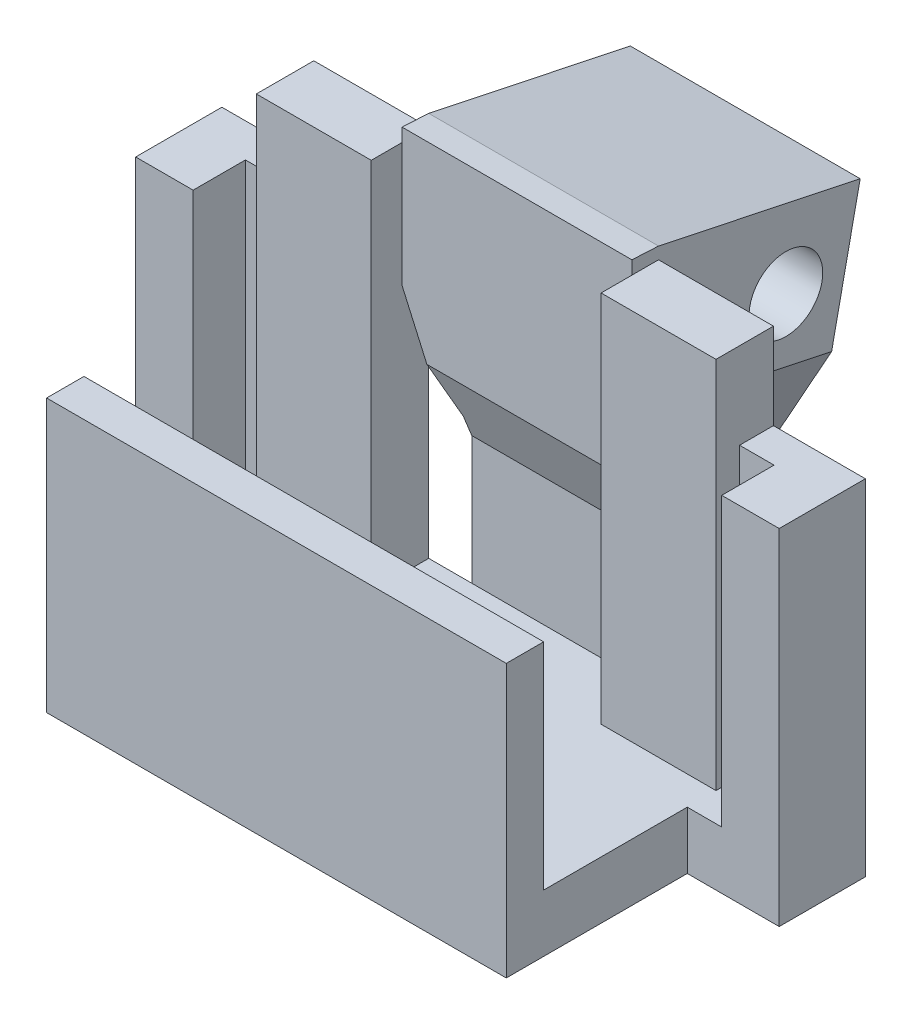
from build123d import *

# Parameters (mm, degrees)
SKETCH_1_W          = 16
SKETCH_1_H          = 6
EXTRUDE_1_DEPTH     = 2
SKETCH_1_3_W        = 16
SKETCH_1_3_H        = 2
SKETCH_1_3_H_2      = 1.5
EXTRUDE_2_DEPTH     = 15
SKETCH_2_W          = 8
SKETCH_2_H          = 26
CUT_EXTRUDE_1_DEPTH = 2
EXTRUDE_3_DEPTH     = 2.5
EXTRUDE_4_DEPTH     = 5
EXTRUDE_5_DEPTH     = 1.5
SKETCH_9_W          = 1.2
SKETCH_9_H          = 1.820432063
EXTRUDE_6_DEPTH     = 2
EXTRUDE_7_DEPTH     = 12
CUT_EXTRUDE_START   = -7.10494
CUT_EXTRUDE_2_DEPTH = 7.10494
SKETCH_12_R         = 1.281793471
CUT_EXTRUDE_3_DEPTH = 10
CUT_EXTRUDE_4_DEPTH = 20.2


with BuildPart() as part:
    # 草图1 → 凸台-拉伸1 (new body)
    with BuildSketch(Plane(origin=(0, 0, 0), x_dir=(1, 0, 0), z_dir=(0, 1, 0))):
        with Locations((0, -0.25)):
            Rectangle(SKETCH_1_W, SKETCH_1_H)
    extrude(amount=EXTRUDE_1_DEPTH)

    # 草图1<3> → 凸台-拉伸2 (add)
    with BuildSketch(Plane(origin=(0, 0, 0), x_dir=(1, 0, 0), z_dir=(0, 1, 0))):
        with Locations((0, 3.75)):
            Rectangle(SKETCH_1_3_W, SKETCH_1_3_H)
        with Locations((0, -4)):
            Rectangle(SKETCH_1_3_W, SKETCH_1_3_H_2)
    extrude(amount=EXTRUDE_2_DEPTH)

    # 草图2 → 切除-拉伸1 (cut)
    with BuildSketch(Plane(origin=(0, 0, -4.75), x_dir=(-1, 0, 0), z_dir=(0, 0, -1))):
        with Locations((0, 15)):
            Rectangle(SKETCH_2_W, SKETCH_2_H)
    extrude(amount=-CUT_EXTRUDE_1_DEPTH, mode=Mode.SUBTRACT)

    # 草图3 → 凸台-拉伸3 (add, symmetric)
    with BuildSketch(Plane(origin=(0, 0, 0), x_dir=(0, 0, -1), z_dir=(1, 0, 0))):
        Polygon((4.75, 0), (8.831597644, 0), (11.768525918, 13.935665169), (4.75, 15.414812878), align=None)
    extrude(amount=EXTRUDE_3_DEPTH, both=True)

    # 草图5 → 凸台-拉伸4 (add)
    with BuildSketch(Plane(origin=(2.5, 0, 0), x_dir=(0, 0, -1), z_dir=(1, 0, 0))):
        Polygon((4.75, 6.451105389), (3.822798244, 8.744995241), (3.822798244, 15.463750373), (4.75, 15.414812878), align=None)
    extrude(amount=-EXTRUDE_4_DEPTH)

    # 草图6 → 凸台-拉伸5 (add)
    with BuildSketch(Plane.ZY.offset(2.5)):
        Polygon((-4.75, 6.451105389), (-10.094945569, 5.994560313), (-11.768525918, 13.935665169), (-4.75, 15.414812878), (-3.822798244, 15.463750373), (-3.822798244, 8.744995241), align=None)
    extrude_5 = extrude(amount=EXTRUDE_5_DEPTH)

    # 草图9 → 凸台-拉伸6 (add)
    with BuildSketch(Plane.XZ):
        with Locations((8.6, -2.660216032)):
            Rectangle(SKETCH_9_W, SKETCH_9_H)
        with Locations((-8.6, -2.660216032)):
            Rectangle(SKETCH_9_W, SKETCH_9_H)
    extrude(amount=-EXTRUDE_6_DEPTH)

    # 草图9<3> → 凸台-拉伸7 (add)
    with BuildSketch(Plane.XZ):
        Polygon((8, -3.570432063), (8, -4.75), (11.2, -4.75), (11.2, -1.75), (9.2, -1.75), (9.2, -3.570432063), align=None)
        Polygon((-8, -4.75), (-8, -3.570432063), (-9.2, -3.570432063), (-9.2, -1.75), (-11.2, -1.75), (-11.2, -4.75), align=None)
    extrude(amount=-EXTRUDE_7_DEPTH)

    # 草图11 → 切除-拉伸2 (cut)
    with BuildSketch(Plane(origin=(0, -1.782098659, -8.456022034), x_dir=(-1, 0, 0), z_dir=(0, -0.206219179, -0.978505825)).offset(CUT_EXTRUDE_START)):
        Polygon((2.5, 7.947483572), (4, 11.245323919), (4, 7.947483572), (4, 5.815044055), (2.5, 5.815044055), align=None)
    cut_extrude_2 = extrude(amount=CUT_EXTRUDE_2_DEPTH, mode=Mode.SUBTRACT)

    # 镜向1: 凸台-拉伸5, 切除-拉伸2 across plane
    add(extrude_5.mirror(Plane(origin=(0, 0, 0), x_dir=(0, 0, 1), z_dir=(1, 0, 0))))
    add(cut_extrude_2.mirror(Plane(origin=(0, 0, 0), x_dir=(0, 0, 1), z_dir=(1, 0, 0))), mode=Mode.SUBTRACT)

    # 草图12 → 切除-拉伸3 (cut)
    with BuildSketch(Plane(origin=(4, 0, 0), x_dir=(0, 0, -1), z_dir=(1, 0, 0))):
        with Locations((9.183579002, 11.7521089)):
            Circle(SKETCH_12_R)
    extrude(amount=-CUT_EXTRUDE_3_DEPTH, mode=Mode.SUBTRACT)

    # 草图13 → 切除-拉伸4 (cut, through all)
    with BuildSketch(Plane(origin=(8, 0, 0), x_dir=(0, 0, -1), z_dir=(1, 0, 0))):
        Polygon((-3.25, 9.484512334), (-4.55, 9.484512334), (-4.55, 0), (-4.75, 0), (-4.75, 15), (-3.25, 15), align=None)
    extrude(amount=-CUT_EXTRUDE_4_DEPTH, mode=Mode.SUBTRACT)


solid = part.part
